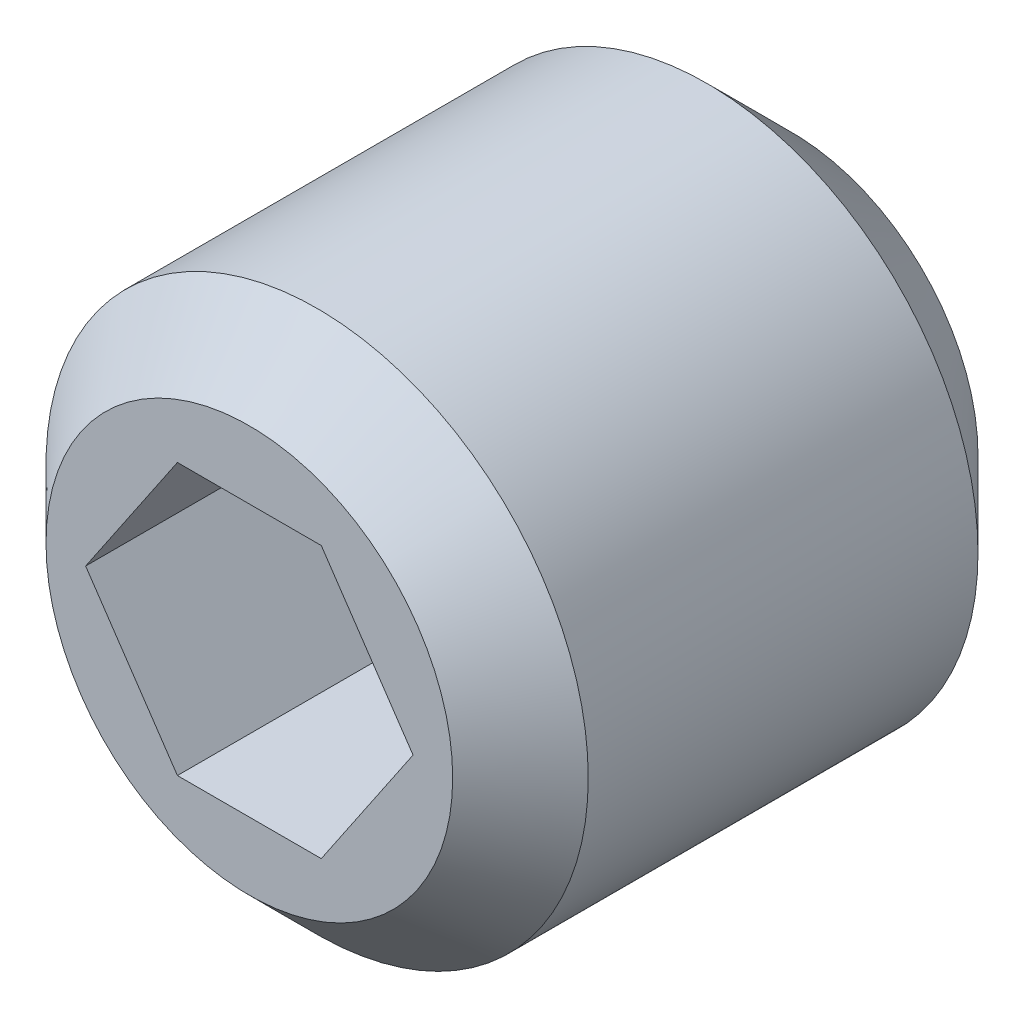
from build123d import *

# Parameters (mm, degrees)
ESQUISSE1_R             = 4
BASE_EXTRUSION_DEPTH    = 8
CHANFREIN1_SIZE         = 1.25
ENL_V_MAT_EXTRU_1_DEPTH = 4
CHANFREIN2_SIZE         = 1


with BuildPart() as part:
    # Esquisse1 → Base-Extrusion (new body)
    with BuildSketch(Plane.XY):
        Circle(ESQUISSE1_R)
    extrude(amount=BASE_EXTRUSION_DEPTH)

    # Chanfrein1
    chanfrein1_edges = [part.edges().sort_by_distance(p)[0] for p in [
        (-4, 0, 0),
    ]]
    chamfer(chanfrein1_edges, length=CHANFREIN1_SIZE)

    # Esquisse2 → Enlèv. mat.-Extru.1 (cut)
    with BuildSketch(Plane.XY.offset(8)):
        Polygon((2.415171399, 0), (1.061268564, 2), (-1.061268564, 2), (-2.415171399, 0), (-1.061268564, -2), (1.061268564, -2), align=None)
    extrude(amount=-ENL_V_MAT_EXTRU_1_DEPTH, mode=Mode.SUBTRACT)

    # Chanfrein2
    chanfrein2_edges = [part.edges().sort_by_distance(p)[0] for p in [
        (-4, 0, 8),
    ]]
    chamfer(chanfrein2_edges, length=CHANFREIN2_SIZE)


solid = part.part
